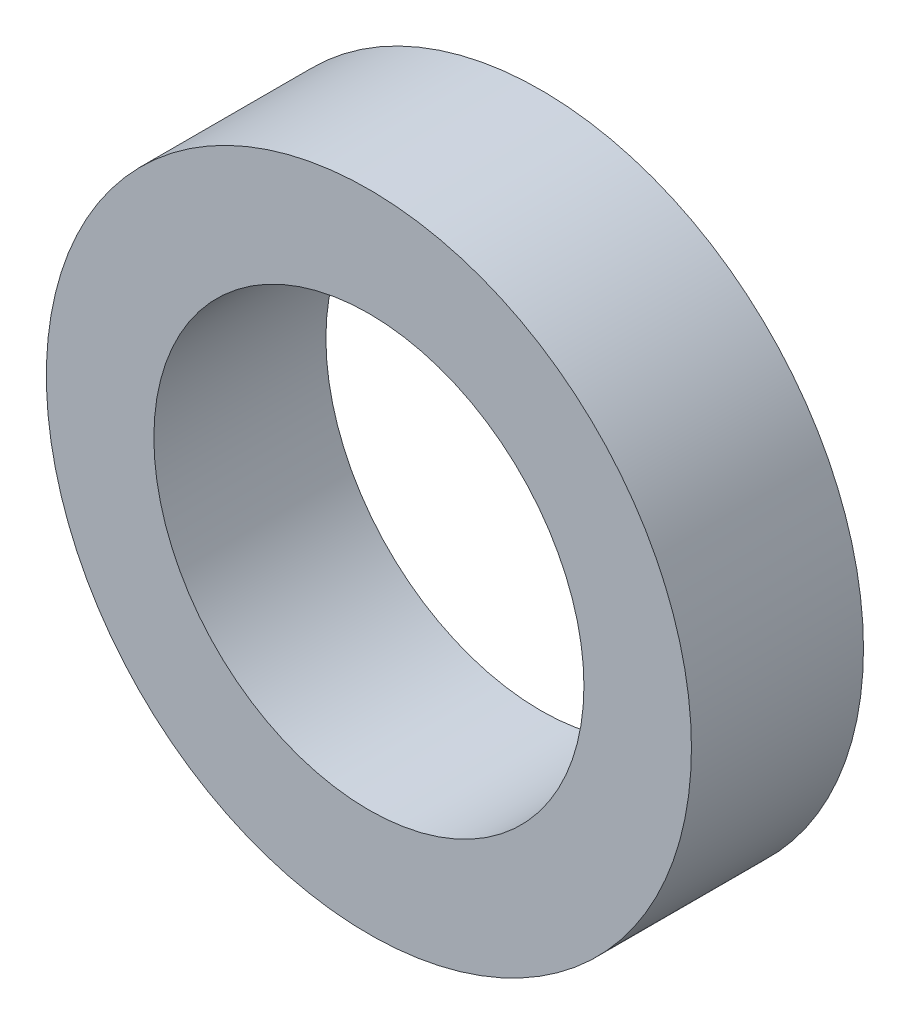
from build123d import *

# Parameters (mm, degrees)
SKETCH_1_R      = 7.5
SKETCH_1_R_2    = 5
EXTRUDE_1_DEPTH = 4


with BuildPart() as part:
    # 草图1 → 凸台-拉伸1 (new body)
    with BuildSketch(Plane.XY):
        Circle(SKETCH_1_R)
        Circle(SKETCH_1_R_2, mode=Mode.SUBTRACT)
    extrude(amount=EXTRUDE_1_DEPTH)


solid = part.part
